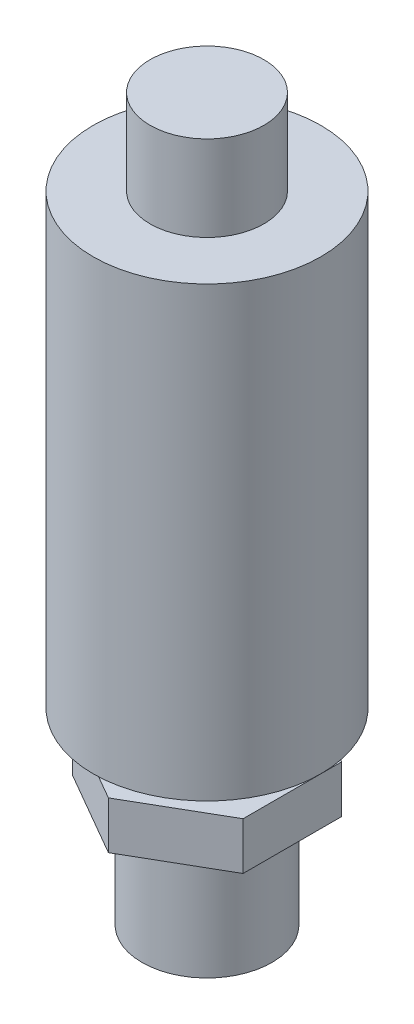
from build123d import *

# Parameters (mm, degrees)
SKETCH1_R           = 6.85
BOSS_EXTRUDE1_DEPTH = 11.8
BOSS_EXTRUDE2_DEPTH = 5
SKETCH3_R           = 5
BOSS_EXTRUDE3_DEPTH = 3
SKETCH4_R           = 12
BOSS_EXTRUDE4_DEPTH = 47.2
SKETCH5_R           = 6
BOSS_EXTRUDE5_DEPTH = 9


with BuildPart() as part:
    # Sketch1 → Boss-Extrude1 (new body)
    with BuildSketch(Plane(origin=(0, 0, 0), x_dir=(1, 0, 0), z_dir=(0, 1, 0))):
        Circle(SKETCH1_R)
    extrude(amount=BOSS_EXTRUDE1_DEPTH)

    # Sketch2 → Boss-Extrude2 (add)
    with BuildSketch(Plane(origin=(0, 11.8, 0), x_dir=(1, 0, 0), z_dir=(0, 1, 0))):
        Polygon((0, 10.392304845), (-9, 5.196152423), (-9, -5.196152423), (0, -10.392304845), (9, -5.196152423), (9, 5.196152423), align=None)
    extrude(amount=BOSS_EXTRUDE2_DEPTH)

    # Sketch3 → Boss-Extrude3 (add)
    with BuildSketch(Plane(origin=(0, 16.8, 0), x_dir=(1, 0, 0), z_dir=(0, 1, 0))):
        Circle(SKETCH3_R)
    extrude(amount=BOSS_EXTRUDE3_DEPTH)

    # Sketch4 → Boss-Extrude4 (add)
    with BuildSketch(Plane(origin=(0, 19.8, 0), x_dir=(1, 0, 0), z_dir=(0, 1, 0))):
        Circle(SKETCH4_R)
    extrude(amount=BOSS_EXTRUDE4_DEPTH)

    # Sketch5 → Boss-Extrude5 (add)
    with BuildSketch(Plane(origin=(0, 67, 0), x_dir=(1, 0, 0), z_dir=(0, 1, 0))):
        Circle(SKETCH5_R)
    extrude(amount=BOSS_EXTRUDE5_DEPTH)


solid = part.part
